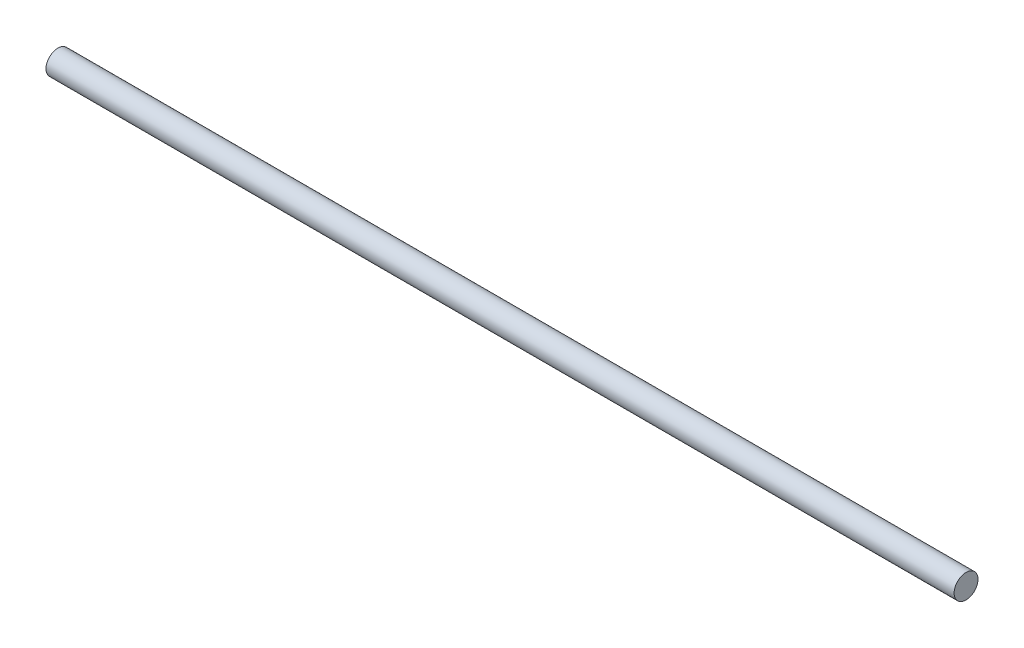
from build123d import *

# Parameters (mm, degrees)
SKETCH1_R           = 4
BOSS_EXTRUDE1_DEPTH = 152


with BuildPart() as part:
    # Sketch1 → Boss-Extrude1 (new body, symmetric)
    with BuildSketch(Plane(origin=(0, 0, 0), x_dir=(0, 0, -1), z_dir=(1, 0, 0))):
        Circle(SKETCH1_R)
    extrude(amount=BOSS_EXTRUDE1_DEPTH, both=True)


solid = part.part
